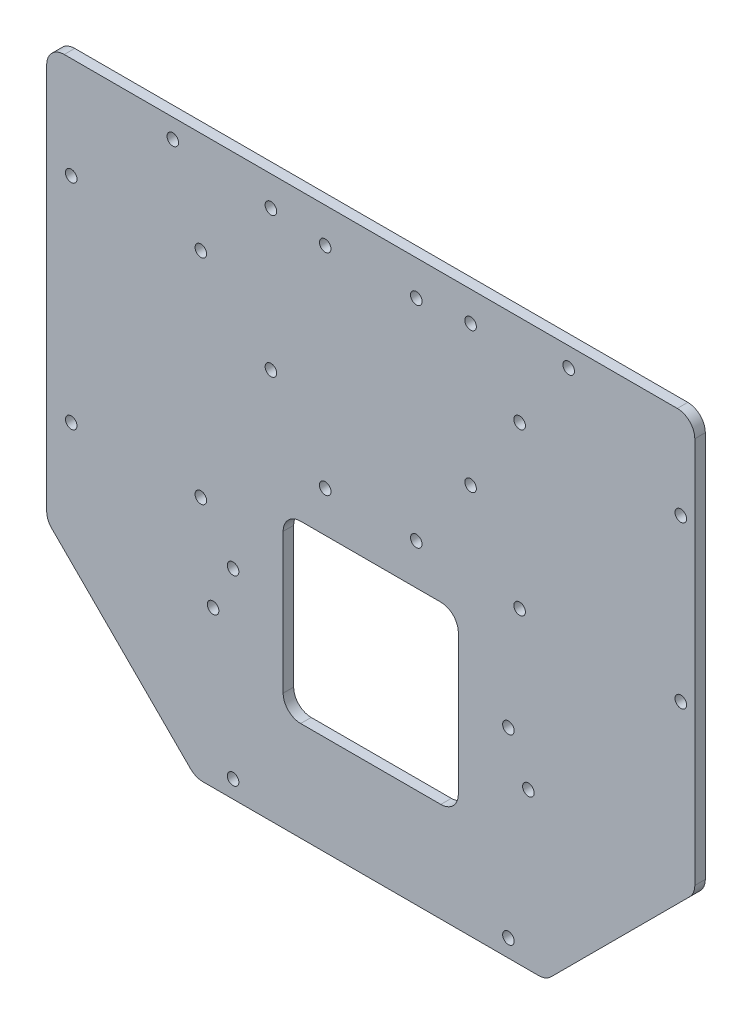
from build123d import *

# Parameters (mm, degrees)
EXTRUDE_1_DEPTH     = 3
SKETCH_2_R          = 1.65
CUT_EXTRUDE_1_DEPTH = 10
SKETCH_3_R          = 1.65
CUT_EXTRUDE_2_DEPTH = 10
SKETCH_4_R          = 1.65
CUT_EXTRUDE_3_DEPTH = 10
SKETCH_5_R          = 1.65
CUT_EXTRUDE_4_DEPTH = 10
SKETCH_6_R          = 1.65
CUT_EXTRUDE_5_DEPTH = 10
SKETCH_7_R          = 1.65
CUT_EXTRUDE_6_DEPTH = 10
CUT_EXTRUDE_7_DEPTH = 10
FILLET_1_R          = 5


with BuildPart() as part:
    # 草图1 → 凸台-拉伸1 (new body)
    with BuildSketch(Plane.XY):
        with BuildLine():
            Line((-87.5, 103.859649123), (87.5, 103.859649123))
            ThreePointArc((87.5, 103.859649123), (91.035533906, 102.395183029), (92.5, 98.859649123))
            Line((92.5, 98.859649123), (92.5, -13.640350877))
            Line((92.5, -13.640350877), (50, -56.140350877))
            Line((50, -56.140350877), (-50, -56.140350877))
            Line((-50, -56.140350877), (-92.5, -13.640350877))
            Line((-92.5, -13.640350877), (-92.5, 98.859649123))
            ThreePointArc((-92.5, 98.859649123), (-91.035533906, 102.395183029), (-87.5, 103.859649123))
        make_face()
    extrude(amount=EXTRUDE_1_DEPTH)

    # 草图2 → 切除-拉伸1 (cut)
    with BuildSketch(Plane.XY.offset(3)):
        with Locations((-28.5, 95.359649123)):
            Circle(SKETCH_2_R)
        with Locations((28.5, 95.359649123)):
            Circle(SKETCH_2_R)
        with Locations((-28.5, 55.359649123)):
            Circle(SKETCH_2_R)
        with Locations((28.5, 55.359649123)):
            Circle(SKETCH_2_R)
    extrude(amount=-CUT_EXTRUDE_1_DEPTH, mode=Mode.SUBTRACT)

    # 草图3 → 切除-拉伸2 (cut)
    with BuildSketch(Plane.XY.offset(3)):
        with Locations((-85.5, 74.859649123)):
            Circle(SKETCH_3_R)
        with Locations((-48.5, 74.859649123)):
            Circle(SKETCH_3_R)
        with Locations((-85.5, 13.859649123)):
            Circle(SKETCH_3_R)
        with Locations((-48.5, 13.859649123)):
            Circle(SKETCH_3_R)
    extrude(amount=-CUT_EXTRUDE_2_DEPTH, mode=Mode.SUBTRACT)

    # 草图4 → 切除-拉伸3 (cut)
    with BuildSketch(Plane.XY.offset(3)):
        with Locations((42.5, 77.859649123)):
            Circle(SKETCH_4_R)
        with Locations((88.5, 77.859649123)):
            Circle(SKETCH_4_R)
        with Locations((42.5, 31.859649123)):
            Circle(SKETCH_4_R)
        with Locations((88.5, 31.859649123)):
            Circle(SKETCH_4_R)
    extrude(amount=-CUT_EXTRUDE_3_DEPTH, mode=Mode.SUBTRACT)

    # 草图5 → 切除-拉伸4 (cut)
    with BuildSketch(Plane.XY.offset(3)):
        with Locations((-39.3, 0.859649123)):
            Circle(SKETCH_5_R)
        with Locations((39.3, 0.859649123)):
            Circle(SKETCH_5_R)
        with Locations((-39.3, -51.140350877)):
            Circle(SKETCH_5_R)
        with Locations((39.3, -51.140350877)):
            Circle(SKETCH_5_R)
    extrude(amount=-CUT_EXTRUDE_4_DEPTH, mode=Mode.SUBTRACT)

    # 草图6 → 切除-拉伸5 (cut)
    with BuildSketch(Plane.XY.offset(3)):
        with Locations((-56.5, 98.359649123)):
            Circle(SKETCH_6_R)
        with Locations((56.5, 98.359649123)):
            Circle(SKETCH_6_R)
        with Locations((-45, -11.640350877)):
            Circle(SKETCH_6_R)
        with Locations((45, -11.640350877)):
            Circle(SKETCH_6_R)
    extrude(amount=-CUT_EXTRUDE_5_DEPTH, mode=Mode.SUBTRACT)

    # 草图7 → 切除-拉伸6 (cut)
    with BuildSketch(Plane.XY.offset(3)):
        with Locations((-13, 93.859649123)):
            Circle(SKETCH_7_R)
        with Locations((13, 93.859649123)):
            Circle(SKETCH_7_R)
        with Locations((13, 33.859649123)):
            Circle(SKETCH_7_R)
        with Locations((-13, 33.859649123)):
            Circle(SKETCH_7_R)
    extrude(amount=-CUT_EXTRUDE_6_DEPTH, mode=Mode.SUBTRACT)

    # 草图8 → 切除-拉伸7 (cut)
    with BuildSketch(Plane.XY.offset(3)):
        with BuildLine():
            Line((-20, 22.217358158), (20, 22.217358158))
            ThreePointArc((20, 22.217358158), (23.535533906, 20.752892063), (25, 17.217358158))
            Line((25, 17.217358158), (25, -22.782641842))
            ThreePointArc((25, -22.782641842), (23.535533906, -26.318175748), (20, -27.782641842))
            Line((20, -27.782641842), (-20, -27.782641842))
            ThreePointArc((-20, -27.782641842), (-23.535533906, -26.318175748), (-25, -22.782641842))
            Line((-25, -22.782641842), (-25, 17.217358158))
            ThreePointArc((-25, 17.217358158), (-23.535533906, 20.752892063), (-20, 22.217358158))
        make_face()
    extrude(amount=-CUT_EXTRUDE_7_DEPTH, mode=Mode.SUBTRACT)

    # 圆角1
    fillet_1_edges = [part.edges().sort_by_distance(p)[0] for p in [
        (-92.5, -13.640350877, 1.5),
        (92.5, -13.640350877, 1.5),
        (50, -56.140350877, 1.5),
        (-50, -56.140350877, 1.5),
    ]]
    fillet(fillet_1_edges, radius=FILLET_1_R)


solid = part.part
